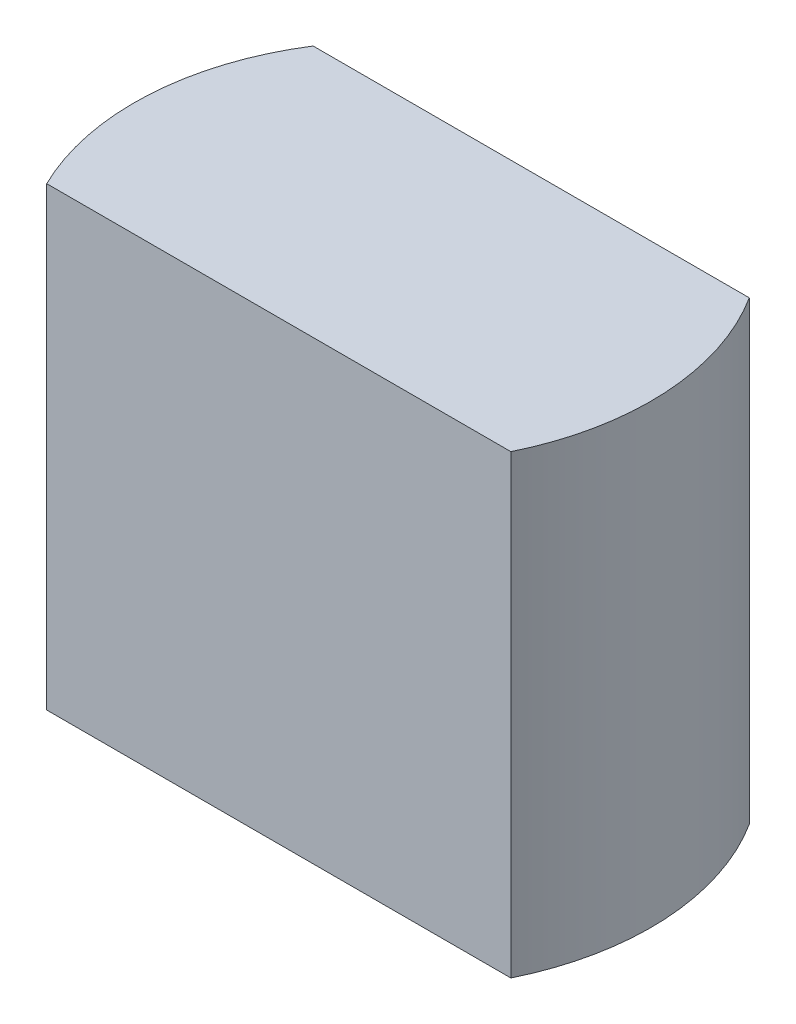
from build123d import *

# Parameters (mm, degrees)
SKETCH1_R           = 4.5
BOSS_EXTRUDE1_DEPTH = 7.9371
SKETCH2_W           = 9.255904856
SKETCH2_H           = 5.023128632
CUT_EXTRUDE1_DEPTH  = 7.9371
SKETCH3_W           = 9.61068527
SKETCH3_H           = 3.540778784
CUT_EXTRUDE2_DEPTH  = 7.9371


with BuildPart() as part:
    # Sketch1 → Boss-Extrude1 (new body)
    with BuildSketch(Plane(origin=(0, 0, 0), x_dir=(1, 0, 0), z_dir=(0, 1, 0))):
        Circle(SKETCH1_R)
    extrude(amount=BOSS_EXTRUDE1_DEPTH)

    # Sketch2 → Cut-Extrude1 (cut)
    with BuildSketch(Plane(origin=(0, 7.9371, 0), x_dir=(1, 0, 0), z_dir=(0, 1, 0))):
        with Locations((-0.035126774, 4.926530004)):
            Rectangle(SKETCH2_W, SKETCH2_H)
    extrude(amount=-CUT_EXTRUDE1_DEPTH, mode=Mode.SUBTRACT)

    # Sketch3 → Cut-Extrude2 (cut)
    with BuildSketch(Plane(origin=(0, 7.9371, 0), x_dir=(1, 0, 0), z_dir=(0, 1, 0))):
        with Locations((0.263450802, -3.750791404)):
            Rectangle(SKETCH3_W, SKETCH3_H)
    extrude(amount=-CUT_EXTRUDE2_DEPTH, mode=Mode.SUBTRACT)


solid = part.part
